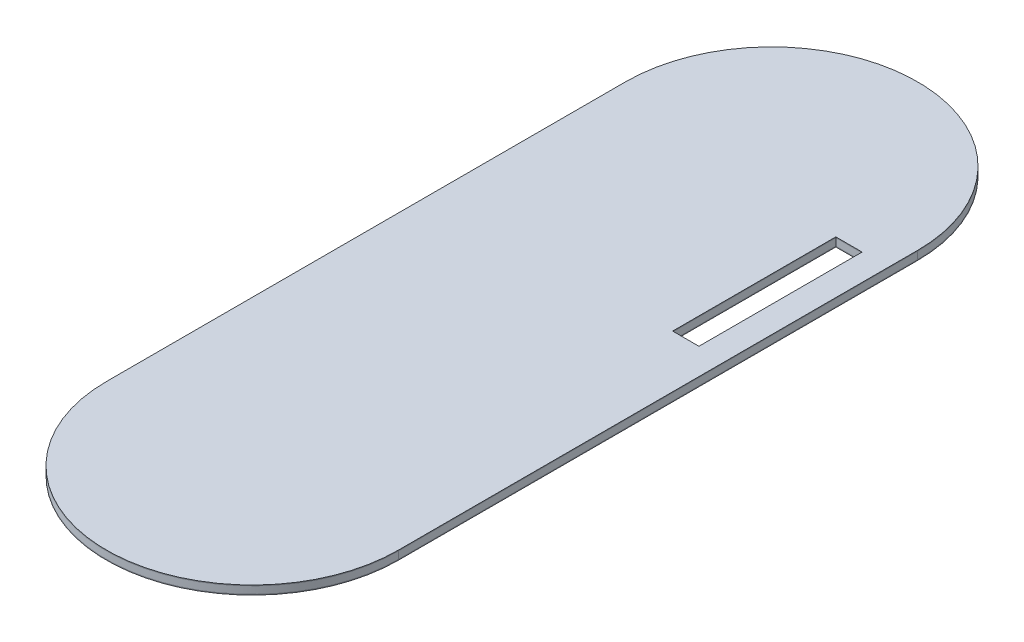
from build123d import *

# Parameters (mm, degrees)
SKETCH1_W           = 9
SKETCH1_H           = 55.88
BOSS_EXTRUDE1_DEPTH = 0.25
SKETCH2_W           = 9
SKETCH2_H           = 55.88
BOSS_EXTRUDE3_DEPTH = 2.5
SKETCH3_W           = 9
SKETCH3_H           = 55.88
BOSS_EXTRUDE4_DEPTH = 0.25


with BuildPart() as part:
    # Sketch1 → Boss-Extrude1 (new body)
    with BuildSketch(Plane(origin=(0, 0, 0), x_dir=(1, 0, 0), z_dir=(0, 1, 0))):
        with BuildLine():
            Line((50, 88.9), (50, -88.9))
            ThreePointArc((50, -88.9), (0, -138.9), (-50, -88.9))
            Line((-50, -88.9), (-50, 88.9))
            ThreePointArc((-50, 88.9), (0, 138.9), (50, 88.9))
        make_face()
        with Locations((36.5, 50.96)):
            Rectangle(SKETCH1_W, SKETCH1_H, mode=Mode.SUBTRACT)
    extrude(amount=BOSS_EXTRUDE1_DEPTH)


with BuildPart() as body_2:
    # Sketch2 → Boss-Extrude3 (new body)
    with BuildSketch(Plane(origin=(0, 0.25, 0), x_dir=(1, 0, 0), z_dir=(0, 1, 0))):
        with BuildLine():
            ThreePointArc((50, 88.9), (0, 138.9), (-50, 88.9))
            Line((-50, 88.9), (-50, -88.9))
            ThreePointArc((-50, -88.9), (0, -138.9), (50, -88.9))
            Line((50, -88.9), (50, 88.9))
        make_face()
        with Locations((36.5, 50.96)):
            Rectangle(SKETCH2_W, SKETCH2_H, mode=Mode.SUBTRACT)
    extrude(amount=BOSS_EXTRUDE3_DEPTH)


with BuildPart() as body_3:
    # Sketch3 → Boss-Extrude4 (new body)
    with BuildSketch(Plane(origin=(0, 2.75, 0), x_dir=(1, 0, 0), z_dir=(0, 1, 0))):
        with BuildLine():
            ThreePointArc((-50, -88.9), (0, -138.9), (50, -88.9))
            Line((50, -88.9), (50, 88.9))
            ThreePointArc((50, 88.9), (0, 138.9), (-50, 88.9))
            Line((-50, 88.9), (-50, -88.9))
        make_face()
        with Locations((36.5, 50.96)):
            Rectangle(SKETCH3_W, SKETCH3_H, mode=Mode.SUBTRACT)
    extrude(amount=BOSS_EXTRUDE4_DEPTH)


solid = Compound([part.part, body_2.part, body_3.part])
